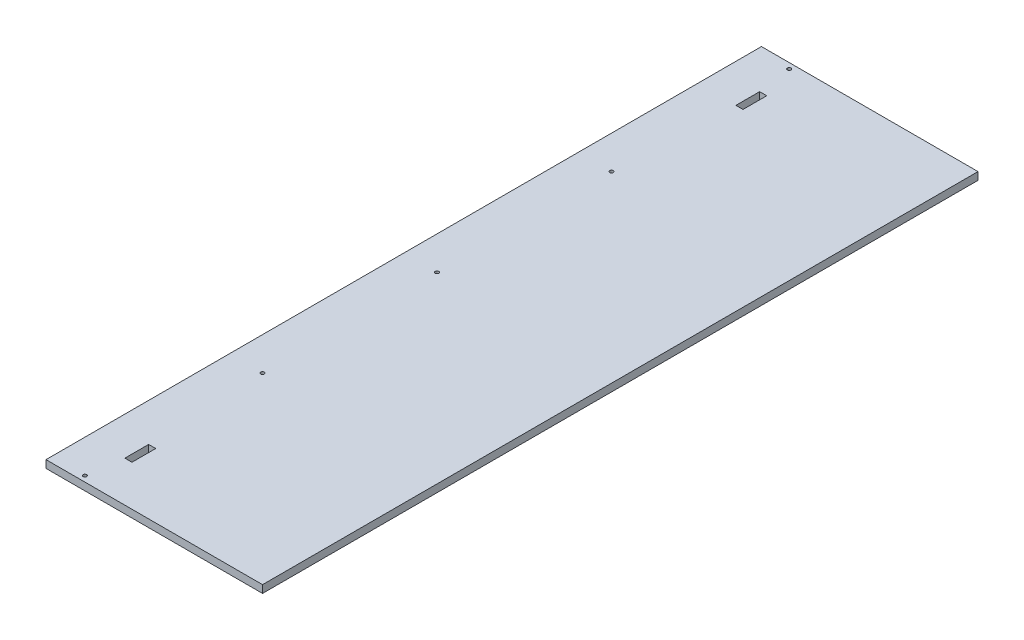
from build123d import *

# Parameters (mm, degrees)
SKETCH1_W           = 100
SKETCH1_H           = 1219.2
BOSS_EXTRUDE1_DEPTH = 13
SKETCH4_R           = 3
CUT_EXTRUDE1_DEPTH  = 20
SKETCH5_W           = 279.735765028
SKETCH5_H           = 13
BOSS_EXTRUDE2_DEPTH = 1219.2
SKETCH6_W           = 12.1
SKETCH6_H           = 40.5
CUT_EXTRUDE2_DEPTH  = 20


with BuildPart() as part:
    # Sketch1 → Boss-Extrude1 (new body)
    with BuildSketch(Plane(origin=(0, 0, 0), x_dir=(1, 0, 0), z_dir=(0, 1, 0))):
        Rectangle(SKETCH1_W, SKETCH1_H)
    extrude(amount=BOSS_EXTRUDE1_DEPTH)

    # Sketch4 → Cut-Extrude1 (cut)
    with BuildSketch(Plane(origin=(0, 13, 0), x_dir=(1, 0, 0), z_dir=(0, 1, 0))):
        with Locations((6.742969062, -600.1)):
            Circle(SKETCH4_R)
        with Locations((6.742969062, -297.3)):
            Circle(SKETCH4_R)
        with Locations((6.742969062, 0)):
            Circle(SKETCH4_R)
        with Locations((6.742969062, 297.3)):
            Circle(SKETCH4_R)
        with Locations((6.742969062, 600.1)):
            Circle(SKETCH4_R)
    extrude(amount=-CUT_EXTRUDE1_DEPTH, mode=Mode.SUBTRACT)

    # Sketch5 → Boss-Extrude2 (add)
    with BuildSketch(Plane.XY.offset(609.6)):
        with Locations((179.132117486, 6.5)):
            Rectangle(SKETCH5_W, SKETCH5_H)
    extrude(amount=-BOSS_EXTRUDE2_DEPTH)

    # Sketch6 → Cut-Extrude2 (cut)
    with BuildSketch(Plane(origin=(0, 13, 0), x_dir=(1, 0, 0), z_dir=(0, 1, 0))):
        with Locations((21.05, -519.97)):
            Rectangle(SKETCH6_W, SKETCH6_H)
        with Locations((21.05, 521.28)):
            Rectangle(SKETCH6_W, SKETCH6_H)
    extrude(amount=-CUT_EXTRUDE2_DEPTH, mode=Mode.SUBTRACT)


solid = part.part
